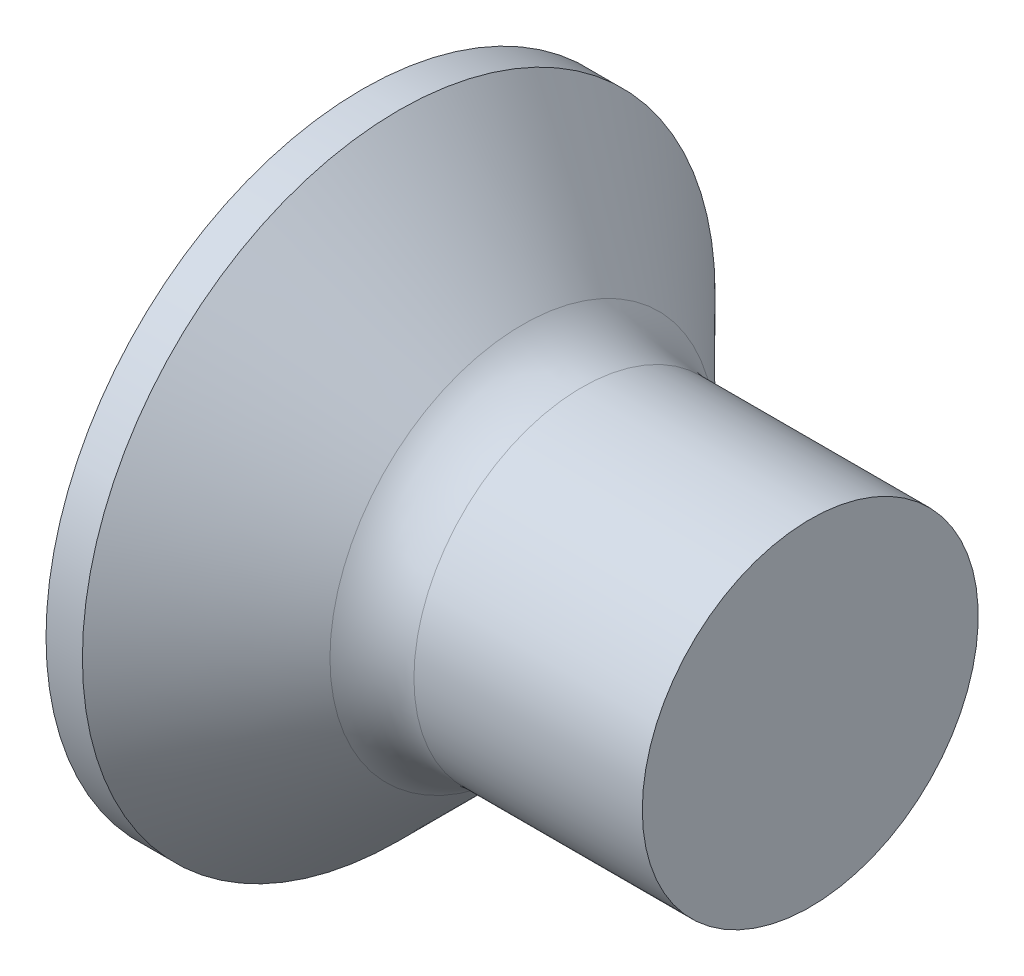
from build123d import *

# Parameters (mm, degrees)
FILLET1_R    = 1.5
SKETCH3_W    = 1.42
SKETCH3_H    = 6.6
SKETCH4_W    = 1.42
SKETCH4_H    = 3.15978748
RECPAT_COUNT = 2
RECPAT_ANGLE = 90


with BuildPart() as part:
    # BodySke → Base-Revolve (revolve)
    with BuildSketch(Plane.XY):
        Polygon((0, 0), (0, 5.65), (0.65, 5.65), (3.3, 3), (8, 3), (8, 0), align=None)
    revolve(axis=Axis((-6.35, 0, 0), (1, 0, 0)))

    # Fillet1
    fillet1_edges = [part.edges().sort_by_distance(p)[0] for p in [
        (3.3, -3, 0),
    ]]
    fillet(fillet1_edges, radius=FILLET1_R)

    # Sketch3 → Recess section 0
    with BuildSketch(Plane.ZY):
        Rectangle(SKETCH3_W, SKETCH3_H)
    # Sketch4 → Recess section 1
    with BuildSketch(Plane.ZY.offset(-3.45)):
        Rectangle(SKETCH4_W, SKETCH4_H)
    recess = loft(mode=Mode.SUBTRACT)

    # RecPat: Recess ×2 about axis
    recpat_axis = Axis((0, 0, 0), (1, 0, 0))
    for i in range(1, RECPAT_COUNT):
        add(recess.rotate(recpat_axis, i * RECPAT_ANGLE / (RECPAT_COUNT - 1)), mode=Mode.SUBTRACT)

    # RecCorSke → RecessCore (revolve, cut)
    with BuildSketch(Plane.XY):
        Polygon((0, 0), (0, 1.521747501), (3.45, 1.2805), (3.866059671, 0), align=None)
    revolve(axis=Axis((-3.175, 0, 0), (1, 0, 0)), mode=Mode.SUBTRACT)


solid = part.part
